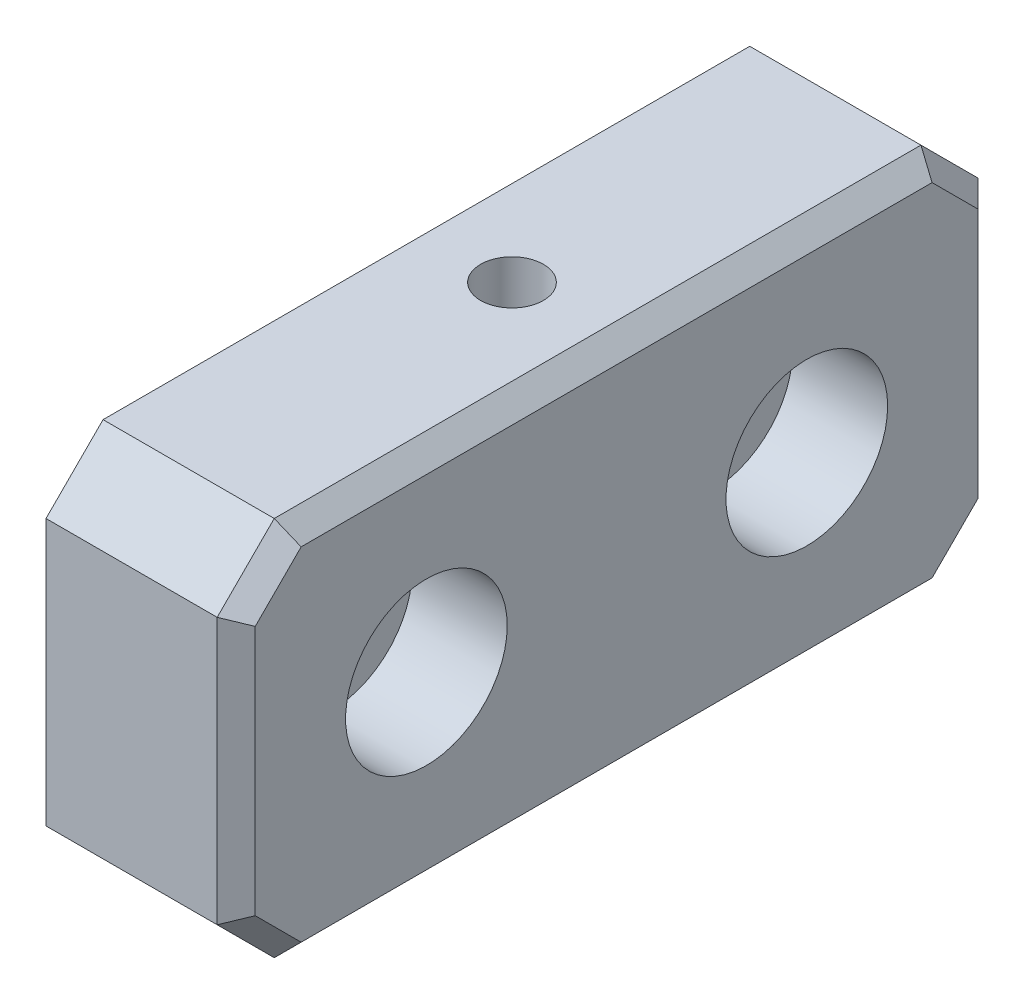
from build123d import *

# Parameters (mm, degrees)
SKETCH1_W           = 40
SKETCH1_H           = 20
BOSS_EXTRUDE1_DEPTH = 10
CHAMFER1_SIZE       = 3
CHAMFER2_SIZE       = 1
SKETCH2_R           = 2.25
CUT_EXTRUDE1_DEPTH  = 10
SKETCH2_3_R         = 4.25
SKETCH2_3_R_2       = 2.25
CUT_EXTRUDE2_DEPTH  = 5
SKETCH3_R           = 1.65
CUT_EXTRUDE3_DEPTH  = 5


with BuildPart() as part:
    # Sketch1 → Boss-Extrude1 (new body)
    with BuildSketch(Plane(origin=(0, 0, 0), x_dir=(0, 0, -1), z_dir=(1, 0, 0))):
        Rectangle(SKETCH1_W, SKETCH1_H)
    extrude(amount=BOSS_EXTRUDE1_DEPTH)

    # Chamfer1
    chamfer1_edges = [part.edges().sort_by_distance(p)[0] for p in [
        (5, 10, -20),
        (5, -10, -20),
        (5, -10, 20),
        (5, 10, 20),
    ]]
    chamfer(chamfer1_edges, length=CHAMFER1_SIZE)

    # Chamfer2
    chamfer2_edges = [part.edges().sort_by_distance(p)[0] for p in [
        (10, -8.5, -18.5),
        (10, -10, 0),
        (10, -8.5, 18.5),
        (10, 0, 20),
        (10, 8.5, 18.5),
        (10, 10, 0),
        (10, 8.5, -18.5),
        (10, 0, -20),
    ]]
    chamfer(chamfer2_edges, length=CHAMFER2_SIZE)

    # Sketch2 → Cut-Extrude1 (cut)
    with BuildSketch(Plane(origin=(10, 0, 0), x_dir=(0, 0, -1), z_dir=(1, 0, 0))):
        with Locations((-10, 0)):
            Circle(SKETCH2_R)
        with Locations((10, 0)):
            Circle(SKETCH2_R)
    extrude(amount=-CUT_EXTRUDE1_DEPTH, mode=Mode.SUBTRACT)

    # Sketch2_3 → Cut-Extrude2 (cut)
    # profile 1 of 2: a face of its own
    with BuildSketch(Plane(origin=(10, 0, 0), x_dir=(0, 0, -1), z_dir=(1, 0, 0))):
        with Locations((-10, 0)):
            Circle(SKETCH2_3_R)
        with Locations((-10, 0)):
            Circle(SKETCH2_3_R_2, mode=Mode.SUBTRACT)
    # profile 2 of 2: a face of its own
    with BuildSketch(Plane(origin=(10, 0, 0), x_dir=(0, 0, -1), z_dir=(1, 0, 0))):
        with Locations((10, 0)):
            Circle(SKETCH2_3_R)
        with Locations((10, 0)):
            Circle(SKETCH2_3_R_2, mode=Mode.SUBTRACT)
    extrude(amount=-CUT_EXTRUDE2_DEPTH, mode=Mode.SUBTRACT)

    # Sketch3 → Cut-Extrude3 (cut)
    with BuildSketch(Plane(origin=(0, 10, 0), x_dir=(1, 0, 0), z_dir=(0, 1, 0))):
        with Locations((4.5, 0)):
            Circle(SKETCH3_R)
    extrude(amount=-CUT_EXTRUDE3_DEPTH, mode=Mode.SUBTRACT)


solid = part.part
